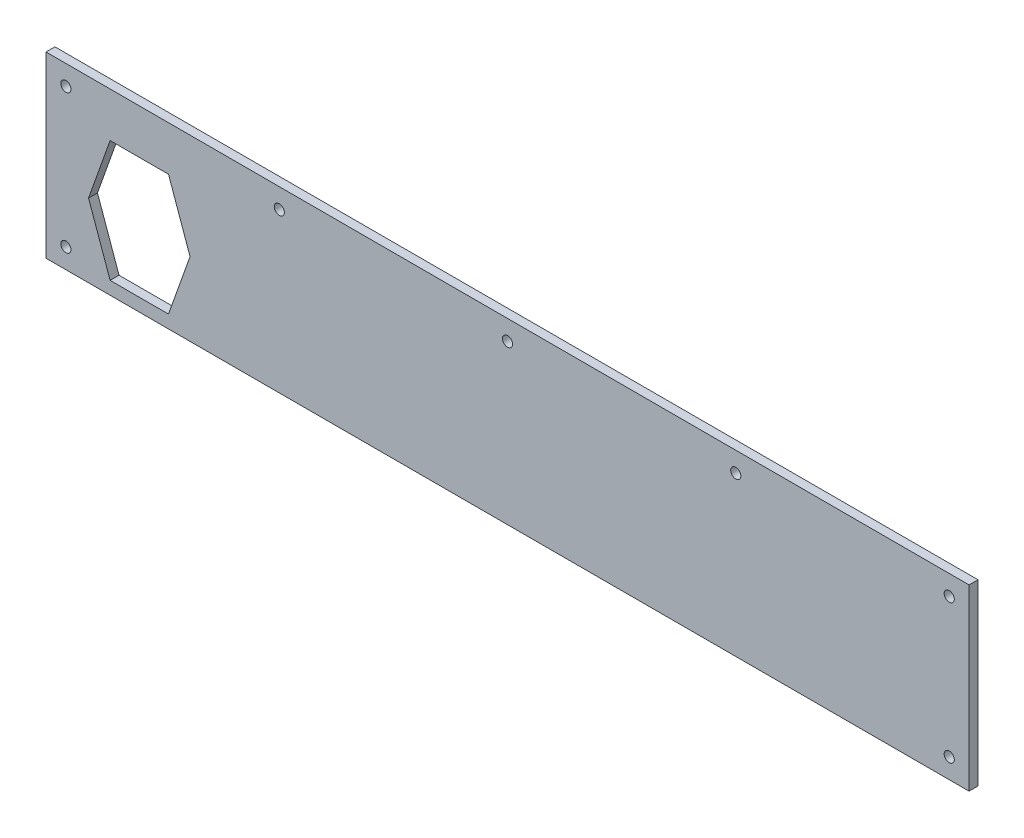
from build123d import *

# Parameters (mm, degrees)
SKETCH1_W           = 465
SKETCH1_H           = 90
SKETCH1_R           = 2.55
BOSS_EXTRUDE1_DEPTH = 2.2479
CUT_EXTRUDE1_REACH  = 6.496


with BuildPart() as part:
    # Sketch1 → Boss-Extrude1 (new body, symmetric)
    with BuildSketch(Plane.XY):
        Rectangle(SKETCH1_W, SKETCH1_H)
        with Locations((-222.5, 35)):
            Circle(SKETCH1_R, mode=Mode.SUBTRACT)
        with Locations((-222.5, -35)):
            Circle(SKETCH1_R, mode=Mode.SUBTRACT)
        with Locations((0, 35)):
            Circle(SKETCH1_R, mode=Mode.SUBTRACT)
        with Locations((-114.975, 35)):
            Circle(SKETCH1_R, mode=Mode.SUBTRACT)
        with Locations((222.5, -35)):
            Circle(SKETCH1_R, mode=Mode.SUBTRACT)
        with Locations((222.5, 35)):
            Circle(SKETCH1_R, mode=Mode.SUBTRACT)
        with Locations((114.975, 35)):
            Circle(SKETCH1_R, mode=Mode.SUBTRACT)
    extrude(amount=BOSS_EXTRUDE1_DEPTH, both=True)

    # Sketch2 → Cut-Extrude1 (cut, up to next)
    with BuildSketch(Plane.XY.offset(2.2479), mode=Mode.PRIVATE) as cut_extrude1_sk1:
        Polygon((-159.938544521, -8), (-170.794476725, 22.5), (-200.205523275, 22.5), (-211.061455479, -8), (-200.205523275, -38.5), (-170.794476725, -38.5), align=None)
    cut_extrude1_tool1 = extrude(cut_extrude1_sk1.sketch, amount=-CUT_EXTRUDE1_REACH, mode=Mode.PRIVATE) & part.part
    add(cut_extrude1_tool1.solids().sort_by_distance((-185.5, -8, 2.2479))[0], mode=Mode.SUBTRACT)


solid = part.part
